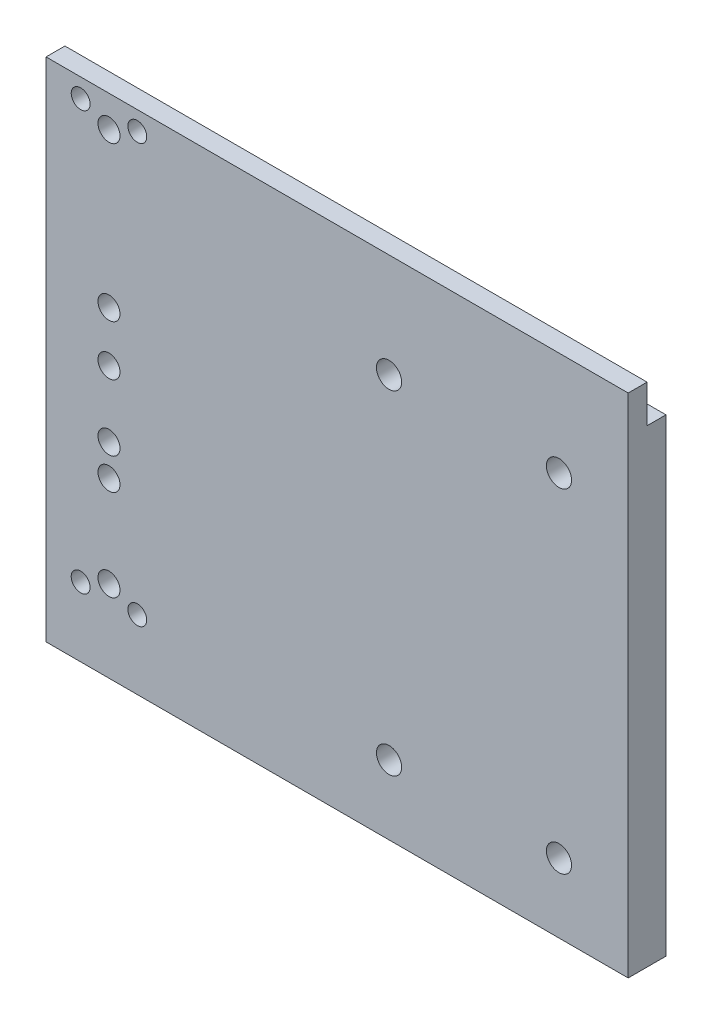
from build123d import *

# Parameters (mm, degrees)
SKETCH1_W           = 97
SKETCH1_H           = 149
SKETCH1_R           = 4
BOSS_EXTRUDE1_DEPTH = 6
SKETCH3_W           = 185
SKETCH3_H           = 161
SKETCH3_R           = 3
SKETCH3_R_2         = 3.5
SKETCH3_R_3         = 4
BOSS_EXTRUDE2_DEPTH = 6


with BuildPart() as part:
    # Sketch1 → Boss-Extrude1 (new body)
    with BuildSketch(Plane.XY):
        with Locations((48.5, 74.5)):
            Rectangle(SKETCH1_W, SKETCH1_H)
        with Locations((21, 128)):
            Circle(SKETCH1_R, mode=Mode.SUBTRACT)
        with Locations((75, 128)):
            Circle(SKETCH1_R, mode=Mode.SUBTRACT)
        with Locations((75, 22)):
            Circle(SKETCH1_R, mode=Mode.SUBTRACT)
        with Locations((21, 22)):
            Circle(SKETCH1_R, mode=Mode.SUBTRACT)
    extrude(amount=-BOSS_EXTRUDE1_DEPTH)

    # Sketch3 → Boss-Extrude2 (add)
    with BuildSketch(Plane.XY):
        with Locations((4.5, 80.5)):
            Rectangle(SKETCH3_W, SKETCH3_H)
        with Locations((-77, 155)):
            Circle(SKETCH3_R, mode=Mode.SUBTRACT)
        with Locations((-59, 22)):
            Circle(SKETCH3_R, mode=Mode.SUBTRACT)
        with Locations((-68, 26)):
            Circle(SKETCH3_R_2, mode=Mode.SUBTRACT)
        with Locations((-77, 22)):
            Circle(SKETCH3_R, mode=Mode.SUBTRACT)
        with Locations((-68, 102)):
            Circle(SKETCH3_R_2, mode=Mode.SUBTRACT)
        with Locations((-68, 86)):
            Circle(SKETCH3_R_2, mode=Mode.SUBTRACT)
        with Locations((-68, 65)):
            Circle(SKETCH3_R_2, mode=Mode.SUBTRACT)
        with Locations((-68, 55)):
            Circle(SKETCH3_R_2, mode=Mode.SUBTRACT)
        with Locations((-59, 155)):
            Circle(SKETCH3_R, mode=Mode.SUBTRACT)
        with Locations((-68, 151)):
            Circle(SKETCH3_R_2, mode=Mode.SUBTRACT)
        with Locations((21, 22)):
            Circle(SKETCH3_R_3, mode=Mode.SUBTRACT)
        with Locations((75, 22)):
            Circle(SKETCH3_R_3, mode=Mode.SUBTRACT)
        with Locations((75, 128)):
            Circle(SKETCH3_R_3, mode=Mode.SUBTRACT)
        with Locations((21, 128)):
            Circle(SKETCH3_R_3, mode=Mode.SUBTRACT)
    extrude(amount=BOSS_EXTRUDE2_DEPTH)


solid = part.part
